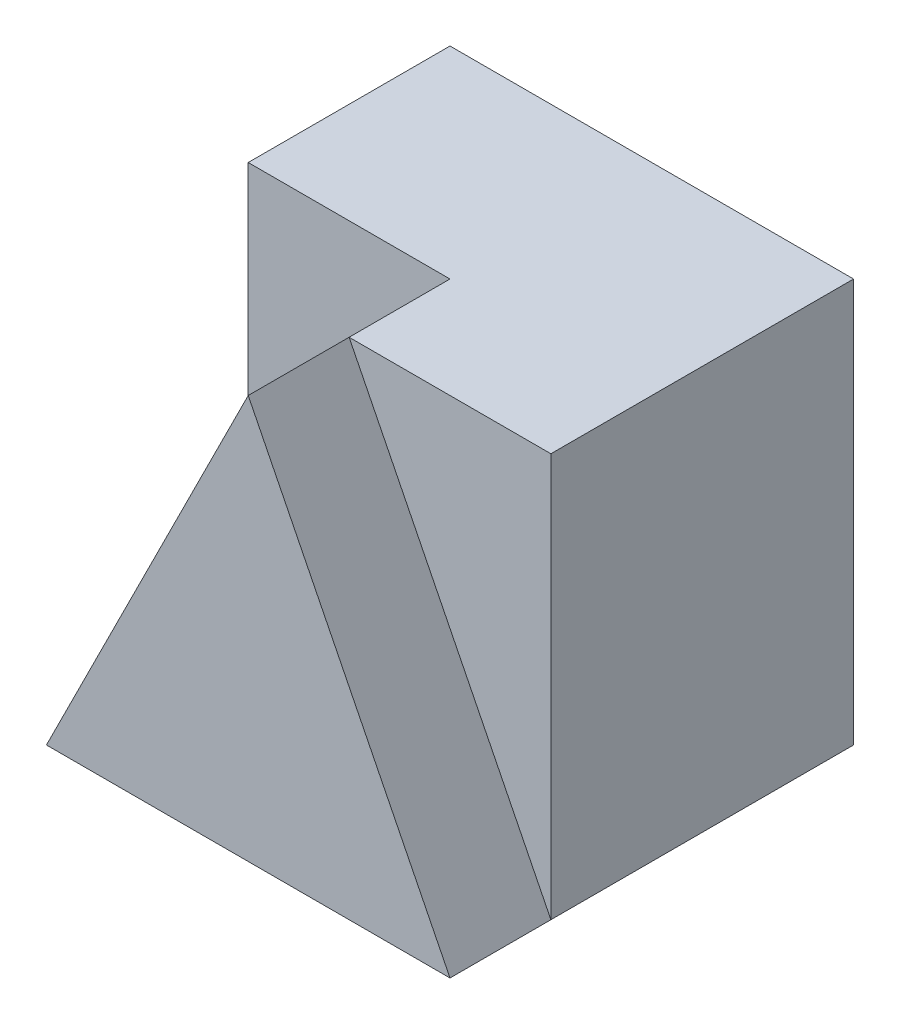
from build123d import *

# Parameters (mm, degrees)
SKETCH1_W           = 4
SKETCH1_H           = 4
BOSS_EXTRUDE1_DEPTH = 4
CUT_EXTRUDE1_DEPTH  = 1
CUT_EXTRUDE2_DEPTH  = 2


with BuildPart() as part:
    # Sketch1 → Boss-Extrude1 (new body)
    with BuildSketch(Plane(origin=(0, 0, 0), x_dir=(1, 0, 0), z_dir=(0, 1, 0))):
        Rectangle(SKETCH1_W, SKETCH1_H)
    extrude(amount=BOSS_EXTRUDE1_DEPTH)

    # Sketch4 → Cut-Extrude1 (cut)
    with BuildSketch(Plane.XY.offset(2)):
        Polygon((0, 4), (2, 4), (2, 0), align=None)
    extrude(amount=-CUT_EXTRUDE1_DEPTH, mode=Mode.SUBTRACT)

    # Sketch5 → Cut-Extrude2 (cut)
    with BuildSketch(Plane.XY.offset(2)):
        Polygon((0, 4), (-2, 0), (-2, 4), align=None)
    extrude(amount=-CUT_EXTRUDE2_DEPTH, mode=Mode.SUBTRACT)


solid = part.part
